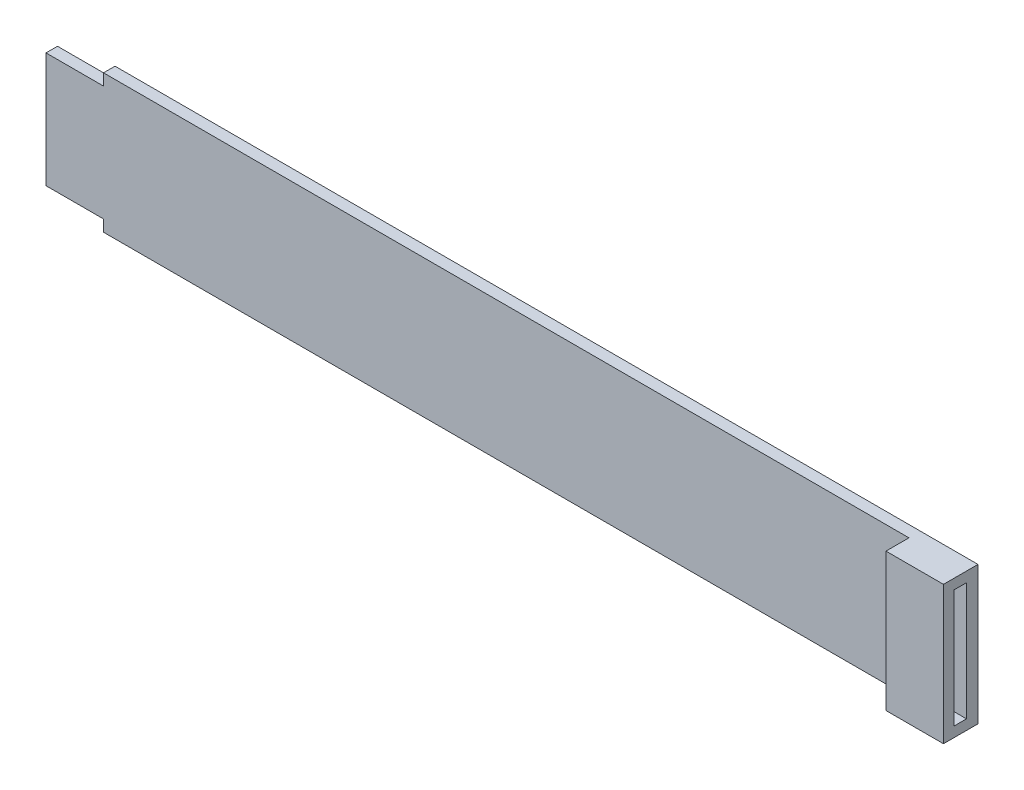
from build123d import *

# Parameters (mm, degrees)
SALIENTE_EXTRUIR1_DEPTH = 2
SALIENTE_EXTRUIR2_DEPTH = 10


with BuildPart() as part:
    # Croquis1 → Saliente-Extruir1 (new body)
    with BuildSketch(Plane.XY):
        Polygon((-8.516541248, 1.295896328), (1.483458752, 1.295896328), (1.483458752, 3.295896328), (151.483458752, 3.295896328), (151.483458752, -20.704103672), (1.483458752, -20.704103672), (1.483458752, -18.704103672), (-8.516541248, -18.704103672), align=None)
    extrude(amount=SALIENTE_EXTRUIR1_DEPTH)

    # Croquis3 → Saliente-Extruir2 (add)
    with BuildSketch(Plane(origin=(151.483458752, 0, 0), x_dir=(0, 0, -1), z_dir=(1, 0, 0))):
        Polygon((-2, 1.545896328), (-2, 3.295896328), (-6, 3.295896328), (-6, -20.704103672), (-2, -20.704103672), (-2, -18.954103672), (-4.2, -18.954103672), (-4.2, 1.545896328), align=None)
    extrude(amount=-SALIENTE_EXTRUIR2_DEPTH)


solid = part.part
